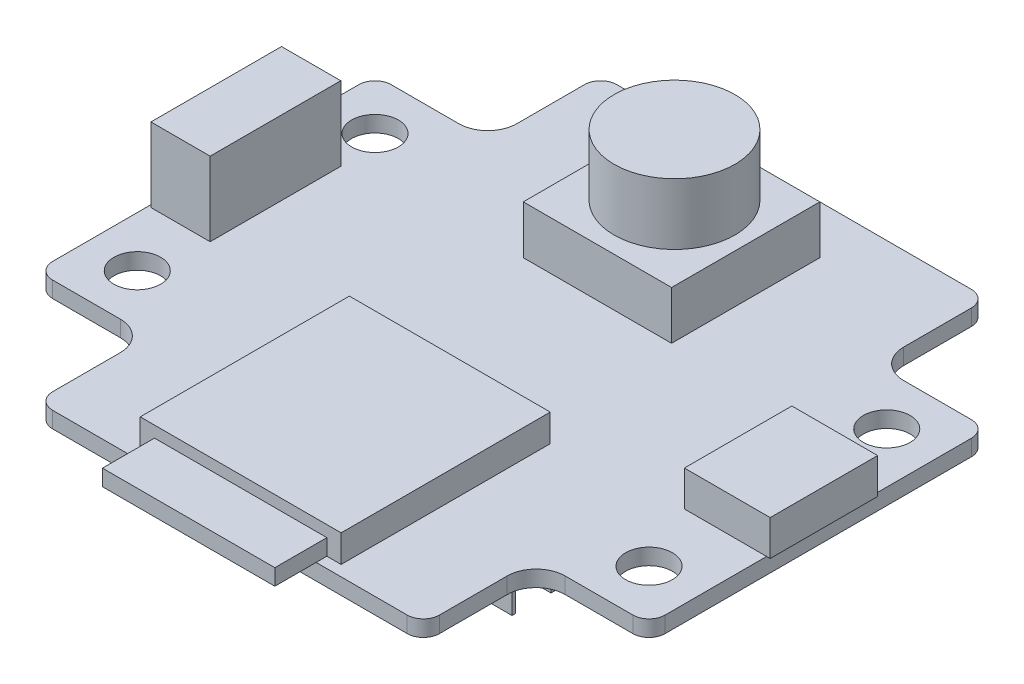
from build123d import *

# Parameters (mm, degrees)
SKETCH_1_R          = 1.45
EXTRUDE_1_DEPTH     = 1
SKETCH_2_W          = 3.674905937
SKETCH_2_H          = 8.103638732
EXTRUDE_2_DEPTH     = 4.6
SKETCH_3_W          = 9.2
SKETCH_3_H          = 9.2
EXTRUDE_3_DEPTH     = 3
SKETCH_4_R          = 3.75
EXTRUDE_4_DEPTH     = 3.8
SKETCH_5_W          = 5.32390219
SKETCH_5_H          = 6.666656283
EXTRUDE_5_DEPTH     = 2.2
SKETCH_6_W          = 12.46284852
SKETCH_6_H          = 12.975244807
EXTRUDE_6_DEPTH     = 1.7
SKETCH_7_W          = 10.69456342
SKETCH_7_H          = 13.354174441
EXTRUDE_7_DEPTH     = 1
SKETCH_8_W          = 14.555394544
SKETCH_8_H          = 14.555394544
EXTRUDE_8_DEPTH     = 6
SKETCH_9_W          = 18.172258066
SKETCH_9_H          = 5.460745639
EXTRUDE_9_DEPTH     = 2.5
SKETCH_10_W         = 17.57536677
SKETCH_10_H         = 2.2
CUT_EXTRUDE_1_DEPTH = 4.5


with BuildPart() as part:
    # 草图1 → 凸台-拉伸1 (new body)
    with BuildSketch(Plane(origin=(0, 0, 0), x_dir=(1, 0, 0), z_dir=(0, 1, 0))):
        with BuildLine():
            Line((-11, 17.5), (11, 17.5))
            ThreePointArc((11, 17.5), (11.707106781, 17.207106781), (12, 16.5))
            Line((12, 16.5), (12, 12.3))
            ThreePointArc((12, 12.3), (12.527207794, 11.027207794), (13.8, 10.5))
            Line((13.8, 10.5), (18, 10.5))
            ThreePointArc((18, 10.5), (18.707106781, 10.207106781), (19, 9.5))
            Line((19, 9.5), (19, -9.5))
            ThreePointArc((19, -9.5), (18.707106781, -10.207106781), (18, -10.5))
            Line((18, -10.5), (13.8, -10.5))
            ThreePointArc((13.8, -10.5), (12.527207794, -11.027207794), (12, -12.3))
            Line((12, -12.3), (12, -16.5))
            ThreePointArc((12, -16.5), (11.707106781, -17.207106781), (11, -17.5))
            Line((11, -17.5), (-11, -17.5))
            ThreePointArc((-11, -17.5), (-11.707106781, -17.207106781), (-12, -16.5))
            Line((-12, -16.5), (-12, -12.3))
            ThreePointArc((-12, -12.3), (-12.527207794, -11.027207794), (-13.8, -10.5))
            Line((-13.8, -10.5), (-18, -10.5))
            ThreePointArc((-18, -10.5), (-18.707106781, -10.207106781), (-19, -9.5))
            Line((-19, -9.5), (-19, 9.5))
            ThreePointArc((-19, 9.5), (-18.707106781, 10.207106781), (-18, 10.5))
            Line((-18, 10.5), (-13.8, 10.5))
            ThreePointArc((-13.8, 10.5), (-12.527207794, 11.027207794), (-12, 12.3))
            Line((-12, 12.3), (-12, 16.5))
            ThreePointArc((-12, 16.5), (-11.707106781, 17.207106781), (-11, 17.5))
        make_face()
        with Locations((15.875, 7.375)):
            Circle(SKETCH_1_R, mode=Mode.SUBTRACT)
        with Locations((15.875, -7.375)):
            Circle(SKETCH_1_R, mode=Mode.SUBTRACT)
        with Locations((-15.875, -7.375)):
            Circle(SKETCH_1_R, mode=Mode.SUBTRACT)
        with Locations((-15.875, 7.375)):
            Circle(SKETCH_1_R, mode=Mode.SUBTRACT)
    extrude(amount=EXTRUDE_1_DEPTH)

    # 草图2 → 凸台-拉伸2 (add)
    with BuildSketch(Plane(origin=(0, 1, 0), x_dir=(1, 0, 0), z_dir=(0, 1, 0))):
        with Locations((-17.008218503, 0.494698876)):
            Rectangle(SKETCH_2_W, SKETCH_2_H)
    extrude(amount=EXTRUDE_2_DEPTH)

    # 草图3 → 凸台-拉伸3 (add)
    with BuildSketch(Plane(origin=(0, 1, 0), x_dir=(1, 0, 0), z_dir=(0, 1, 0))):
        with Locations((0, 9.9)):
            Rectangle(SKETCH_3_W, SKETCH_3_H)
    extrude(amount=EXTRUDE_3_DEPTH)

    # 草图4 → 凸台-拉伸4 (add)
    with BuildSketch(Plane(origin=(0, 4, 0), x_dir=(1, 0, 0), z_dir=(0, 1, 0))):
        with Locations((0, 10.082434237)):
            Circle(SKETCH_4_R)
    extrude(amount=EXTRUDE_4_DEPTH)

    # 草图5 → 凸台-拉伸5 (add)
    with BuildSketch(Plane(origin=(0, 1, 0), x_dir=(1, 0, 0), z_dir=(0, 1, 0))):
        with Locations((16.560633805, 0.129563992)):
            Rectangle(SKETCH_5_W, SKETCH_5_H)
    extrude(amount=EXTRUDE_5_DEPTH)

    # 草图6 → 凸台-拉伸6 (add)
    with BuildSketch(Plane(origin=(0, 1, 0), x_dir=(1, 0, 0), z_dir=(0, 1, 0))):
        with Locations((0, -10.346273638)):
            Rectangle(SKETCH_6_W, SKETCH_6_H)
    extrude(amount=EXTRUDE_6_DEPTH)

    # 草图7 → 凸台-拉伸7 (add)
    with BuildSketch(Plane(origin=(0, 1, 0), x_dir=(1, 0, 0), z_dir=(0, 1, 0))):
        with Locations((0, -13.384558474)):
            Rectangle(SKETCH_7_W, SKETCH_7_H)
    extrude(amount=EXTRUDE_7_DEPTH)

    # 草图8 → 凸台-拉伸8 (add)
    with BuildSketch(Plane.XZ):
        Rectangle(SKETCH_8_W, SKETCH_8_H)
    extrude(amount=EXTRUDE_8_DEPTH)

    # 草图9 → 凸台-拉伸9 (add)
    with BuildSketch(Plane.XZ):
        with Locations((0, -13.73622766)):
            Rectangle(SKETCH_9_W, SKETCH_9_H)
    extrude(amount=EXTRUDE_9_DEPTH)

    # 草图10 → 切除-拉伸1 (cut)
    with BuildSketch(Plane.XZ.offset(6)):
        with Locations((-0.008749504, 5.958042987)):
            Rectangle(SKETCH_10_W, SKETCH_10_H)
        with Locations((-0.008749504, 2.958042987)):
            Rectangle(SKETCH_10_W, SKETCH_10_H)
        with Locations((-0.008749504, -0.041957013)):
            Rectangle(SKETCH_10_W, SKETCH_10_H)
        with Locations((-0.008749504, -3.041957013)):
            Rectangle(SKETCH_10_W, SKETCH_10_H)
        with Locations((-0.008749504, -6.041957013)):
            Rectangle(SKETCH_10_W, SKETCH_10_H)
    extrude(amount=-CUT_EXTRUDE_1_DEPTH, mode=Mode.SUBTRACT)


solid = part.part
